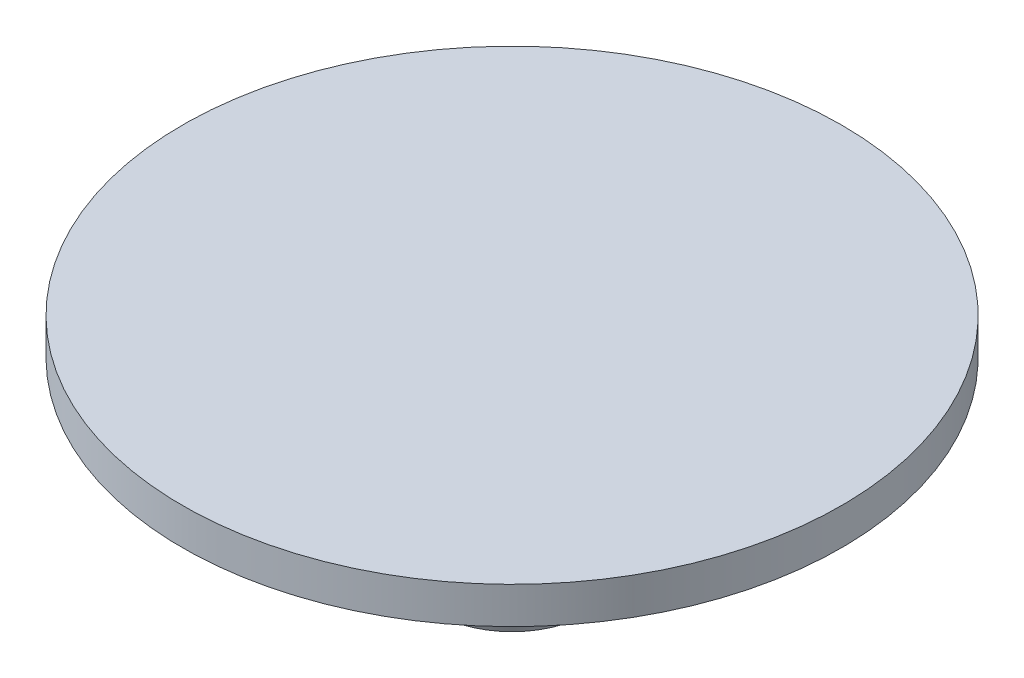
from build123d import *


with BuildPart() as part:
    # Sketch1 → Revolve1 (revolve)
    with BuildSketch(Plane.XY):
        Polygon((0, 0), (0, 6), (-9, 6), (-9, 5), (-2.1, 5), (-2.1, 3), (-3, 3), (-2.1, 0), align=None)
    revolve(axis=Axis((0, 0, 0), (0, 1, 0)))


solid = part.part
